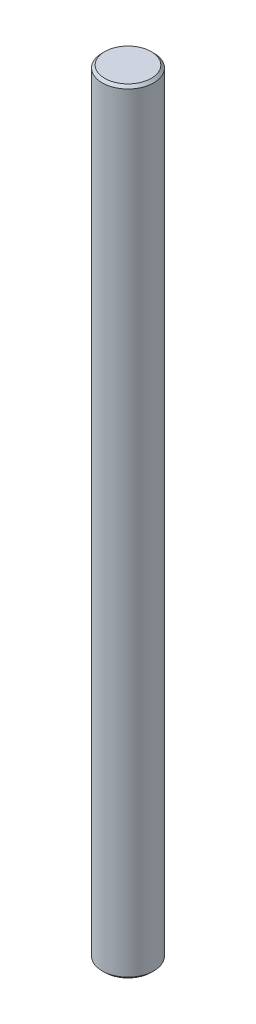
from build123d import *

# Parameters (mm, degrees)
SKETCH1_R           = 10
BOSS_EXTRUDE1_DEPTH = 300
CHAMFER1_SIZE       = 1


with BuildPart() as part:
    # Sketch1 → Boss-Extrude1 (new body)
    with BuildSketch(Plane(origin=(0, 0, 0), x_dir=(1, 0, 0), z_dir=(0, 1, 0))):
        Circle(SKETCH1_R)
    extrude(amount=BOSS_EXTRUDE1_DEPTH)

    # Chamfer1
    chamfer1_edges = [part.edges().sort_by_distance(p)[0] for p in [
        (-10, 0, 0),
        (-10, 300, 0),
    ]]
    chamfer(chamfer1_edges, length=CHAMFER1_SIZE)


solid = part.part
